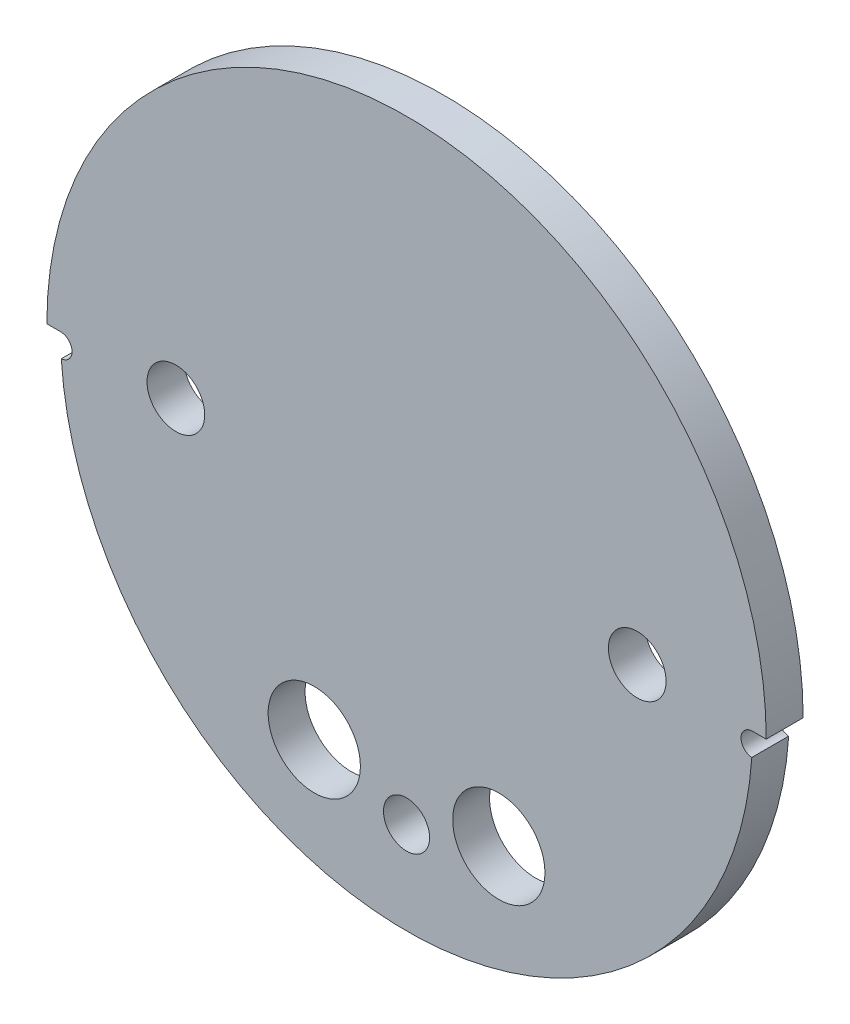
from build123d import *
from build123d.topology import SkipClean

# Parameters (mm, degrees)
SKETCH1_R           = 49.5046
BOSS_EXTRUDE1_DEPTH = 5.08
SKETCH2_R           = 47.625
BOSS_EXTRUDE2_DEPTH = 3.175
SKETCH3_R           = 3.96875
SKETCH3_R_2         = 6.35
CUT_EXTRUDE1_DEPTH  = 71.495076901
CUT_EXTRUDE2_DEPTH  = 71.194139658
SKETCH5_R           = 54.412278645
CUT_EXTRUDE3_DEPTH  = 3.175
SKETCH6_R           = 1.5875
CUT_EXTRUDE4_DEPTH  = 71.194139658
SKETCH7_R           = 3.175
CUT_EXTRUDE5_DEPTH  = 71.194139658


with BuildPart() as part:
    # Sketch1 → Boss-Extrude1 (new body)
    with BuildSketch(Plane.XY):
        Circle(SKETCH1_R)
    extrude(amount=BOSS_EXTRUDE1_DEPTH)

    # Sketch2 → Boss-Extrude2 (add)
    with BuildSketch(Plane.XY.offset(5.08)):
        Circle(SKETCH2_R)
    extrude(amount=BOSS_EXTRUDE2_DEPTH)

    # Sketch3 → Cut-Extrude1 (cut, through all)
    with BuildSketch(Plane.XY.offset(8.255)):
        with Locations((-31.75, 0)):
            Circle(SKETCH3_R)
        with Locations((31.75, 0)):
            Circle(SKETCH3_R)
        with Locations((-12.7, -31.166793627)):
            Circle(SKETCH3_R_2)
        with Locations((12.7, -31.166793627)):
            Circle(SKETCH3_R_2)
    extrude(amount=-CUT_EXTRUDE1_DEPTH, mode=Mode.SUBTRACT)

    # Sketch4 → Cut-Extrude2 (cut, through all)
    with SkipClean():  # the faces are left unmerged after this step: merging them gives an invalid solid
        with BuildSketch(Plane.XY.offset(5.08)):
            with BuildLine():
                Line((-50.165, 0), (-47.625, 0))
                ThreePointArc((-47.625, 0), (0, -47.625), (47.625, 0))
                Line((47.625, 0), (50.165, 0))
                ThreePointArc((50.165, 0), (0, -50.165), (-50.165, 0))
            make_face()
        extrude(amount=-CUT_EXTRUDE2_DEPTH, mode=Mode.SUBTRACT)

    # Sketch5 → Cut-Extrude3 (cut)
    with BuildSketch(Plane.XY.offset(8.255)):
        Circle(SKETCH5_R)
    extrude(amount=-CUT_EXTRUDE3_DEPTH, mode=Mode.SUBTRACT)

    # Sketch6 → Cut-Extrude4 (cut, through all)
    with BuildSketch(Plane(origin=(0, 0, 0), x_dir=(-1, 0, 0), z_dir=(0, 0, -1))):
        with Locations((-47.625, -1.5875)):
            Circle(SKETCH6_R)
        with Locations((47.625, -1.5875)):
            Circle(SKETCH6_R)
    extrude(amount=-CUT_EXTRUDE4_DEPTH, mode=Mode.SUBTRACT)

    # Sketch7 → Cut-Extrude5 (cut, through all)
    with BuildSketch(Plane.XY.offset(5.08)):
        with Locations((0, -34.925)):
            Circle(SKETCH7_R)
    extrude(amount=-CUT_EXTRUDE5_DEPTH, mode=Mode.SUBTRACT)


solid = part.part
